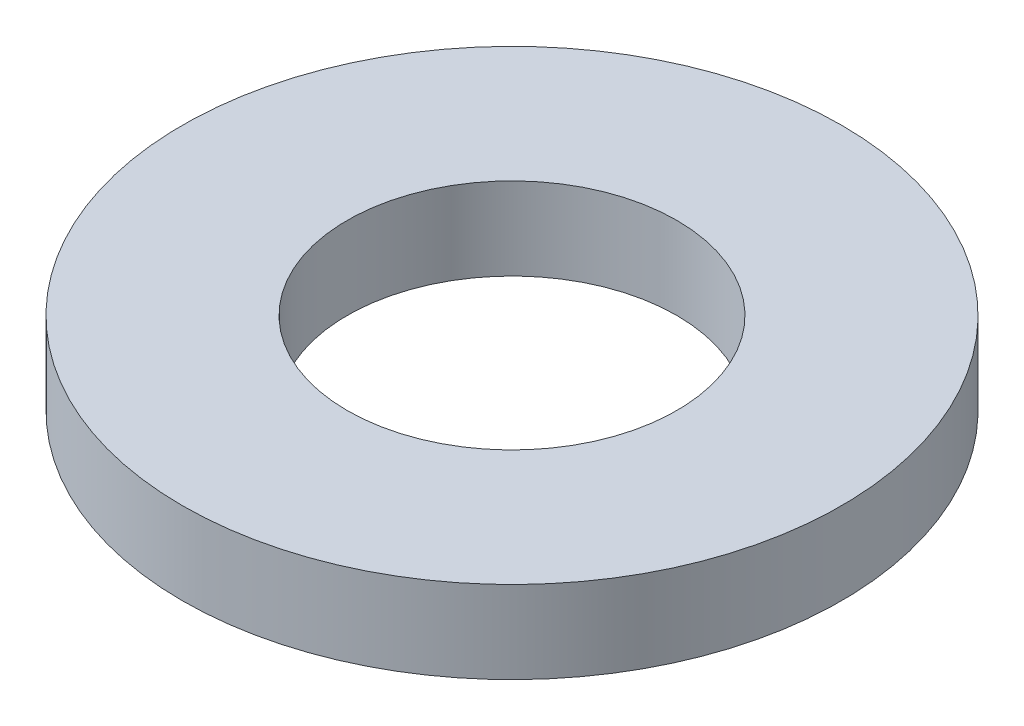
from build123d import *

# Parameters (mm, degrees)
SKETCH1_R           = 4
SKETCH1_R_2         = 2
BOSS_EXTRUDE1_DEPTH = 1


with BuildPart() as part:
    # Sketch1 → Boss-Extrude1 (new body)
    with BuildSketch(Plane(origin=(0, 0, 0), x_dir=(1, 0, 0), z_dir=(0, 1, 0))):
        Circle(SKETCH1_R)
        Circle(SKETCH1_R_2, mode=Mode.SUBTRACT)
    extrude(amount=BOSS_EXTRUDE1_DEPTH)


solid = part.part
